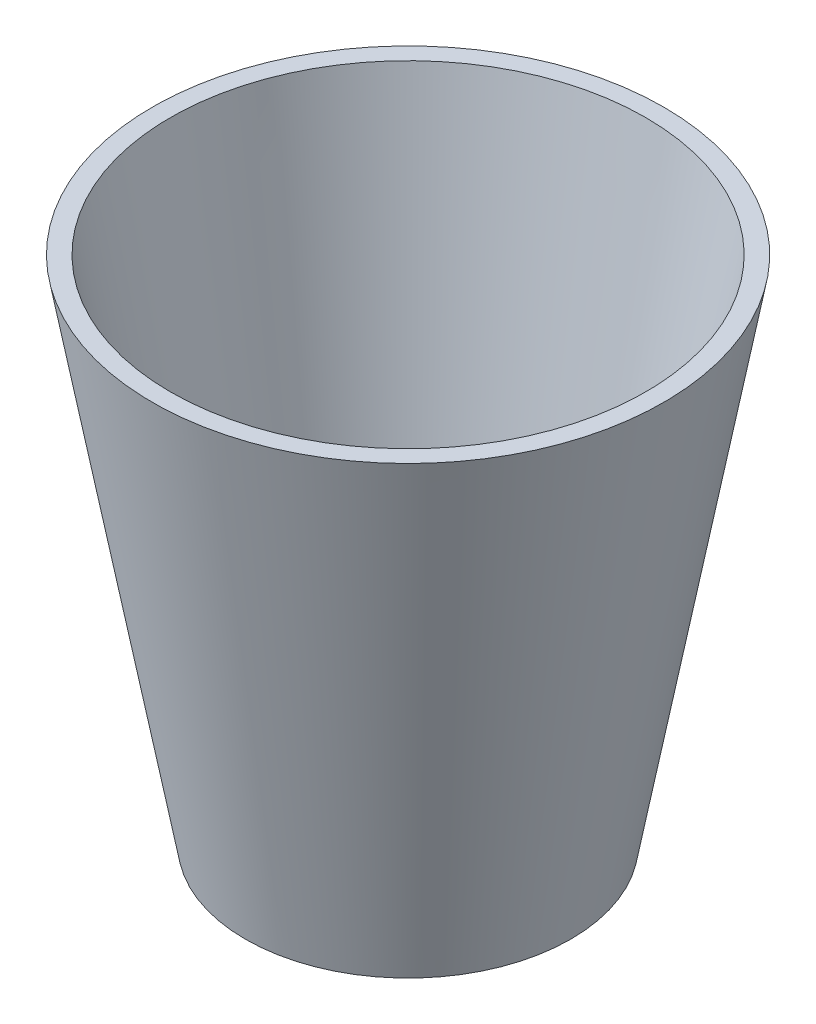
from build123d import *


with BuildPart() as part:
    # Esboço1 → Revolução1 (revolve)
    with BuildSketch(Plane.XY):
        Polygon((0, 0), (17.5, 0), (27.5, 55), (25.557496218, 55), (15.639013807, 1.441484911), (0, 0.993721243), align=None)
    revolve(axis=Axis((0, 0, 0), (0, 1, 0)))


solid = part.part
